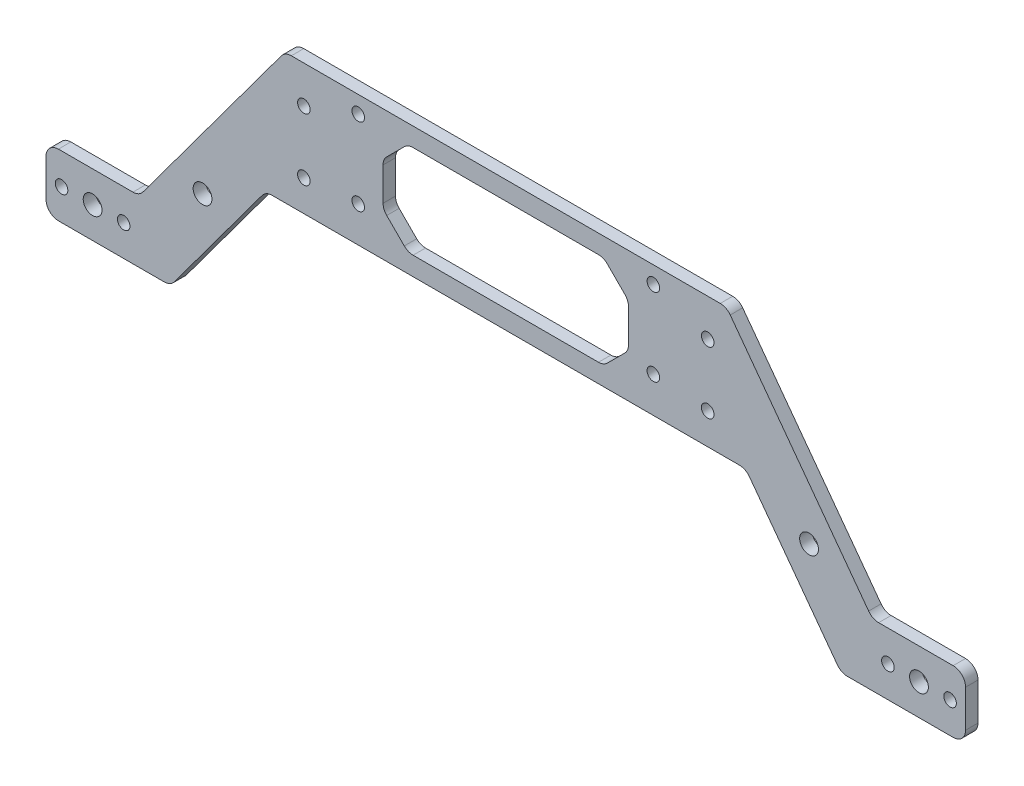
from build123d import *

# Parameters (mm, degrees)
SKETCH_1_R          = 3.025
SKETCH_1_R_2        = 2.025
EXTRUDE_1_DEPTH     = 4
SKETCH_2_W          = 79
SKETCH_2_H          = 30
CUT_EXTRUDE_1_DEPTH = 4
FILLET_1_R          = 4
CHAMFER_1_SIZE      = 8
FILLET_2_R          = 4


with BuildPart() as part:
    # 草图1 → 凸台-拉伸1 (new body)
    with BuildSketch(Plane.XY):
        Polygon((-71.051486421, 22), (-118, -41.5), (-148, -41.5), (-148, -61.5), (-107.914189298, -61.5), (-77.231302471, -20), (77.231302471, -20), (107.914189298, -61.5), (148, -61.5), (148, -41.5), (118, -41.5), (71.051486421, 22), align=None)
        with Locations((-97.615651235, -30.75)):
            Circle(SKETCH_1_R, mode=Mode.SUBTRACT)
        with Locations((97.615651235, -30.75)):
            Circle(SKETCH_1_R, mode=Mode.SUBTRACT)
        with Locations((-65, -10)):
            Circle(SKETCH_1_R_2, mode=Mode.SUBTRACT)
        with Locations((-47.5, -8.5)):
            Circle(SKETCH_1_R_2, mode=Mode.SUBTRACT)
        with Locations((-65, 10)):
            Circle(SKETCH_1_R_2, mode=Mode.SUBTRACT)
        with Locations((-47.5, 16.5)):
            Circle(SKETCH_1_R_2, mode=Mode.SUBTRACT)
        with Locations((65, -10)):
            Circle(SKETCH_1_R_2, mode=Mode.SUBTRACT)
        with Locations((47.5, -8.5)):
            Circle(SKETCH_1_R_2, mode=Mode.SUBTRACT)
        with Locations((65, 10)):
            Circle(SKETCH_1_R_2, mode=Mode.SUBTRACT)
        with Locations((47.5, 16.5)):
            Circle(SKETCH_1_R_2, mode=Mode.SUBTRACT)
        with Locations((-123, -51.5)):
            Circle(SKETCH_1_R_2, mode=Mode.SUBTRACT)
        with Locations((-143, -51.5)):
            Circle(SKETCH_1_R_2, mode=Mode.SUBTRACT)
        with Locations((-133, -51.5)):
            Circle(SKETCH_1_R, mode=Mode.SUBTRACT)
        with Locations((143, -51.5)):
            Circle(SKETCH_1_R_2, mode=Mode.SUBTRACT)
        with Locations((123, -51.5)):
            Circle(SKETCH_1_R_2, mode=Mode.SUBTRACT)
        with Locations((133, -51.5)):
            Circle(SKETCH_1_R, mode=Mode.SUBTRACT)
    extrude(amount=EXTRUDE_1_DEPTH)

    # 草图2 → 切除-拉伸1 (cut)
    with BuildSketch(Plane.XY.offset(4)):
        with Locations((0, 1)):
            Rectangle(SKETCH_2_W, SKETCH_2_H)
    extrude(amount=-CUT_EXTRUDE_1_DEPTH, mode=Mode.SUBTRACT)

    # 圆角1
    fillet_1_edges = [part.edges().sort_by_distance(p)[0] for p in [
        (-148, -61.5, 2),
        (-148, -41.5, 2),
        (-118, -41.5, 2),
        (-71.051486421, 22, 2),
        (71.051486421, 22, 2),
        (118, -41.5, 2),
        (148, -41.5, 2),
        (148, -61.5, 2),
        (107.914189298, -61.5, 2),
        (77.231302471, -20, 2),
        (-77.231302471, -20, 2),
        (-107.914189298, -61.5, 2),
    ]]
    fillet(fillet_1_edges, radius=FILLET_1_R)

    # 倒角1
    chamfer_1_edges = [part.edges().sort_by_distance(p)[0] for p in [
        (39.5, 16, 2),
        (39.5, -14, 2),
        (-39.5, -14, 2),
        (-39.5, 16, 2),
    ]]
    chamfer(chamfer_1_edges, length=CHAMFER_1_SIZE)

    # 圆角2
    fillet_2_edges = [part.edges().sort_by_distance(p)[0] for p in [
        (39.5, 8, 2),
        (39.5, -6, 2),
        (-31.5, -14, 2),
        (31.5, -14, 2),
        (-31.5, 16, 2),
        (31.5, 16, 2),
        (-39.5, -6, 2),
        (-39.5, 8, 2),
    ]]
    fillet(fillet_2_edges, radius=FILLET_2_R)


solid = part.part
